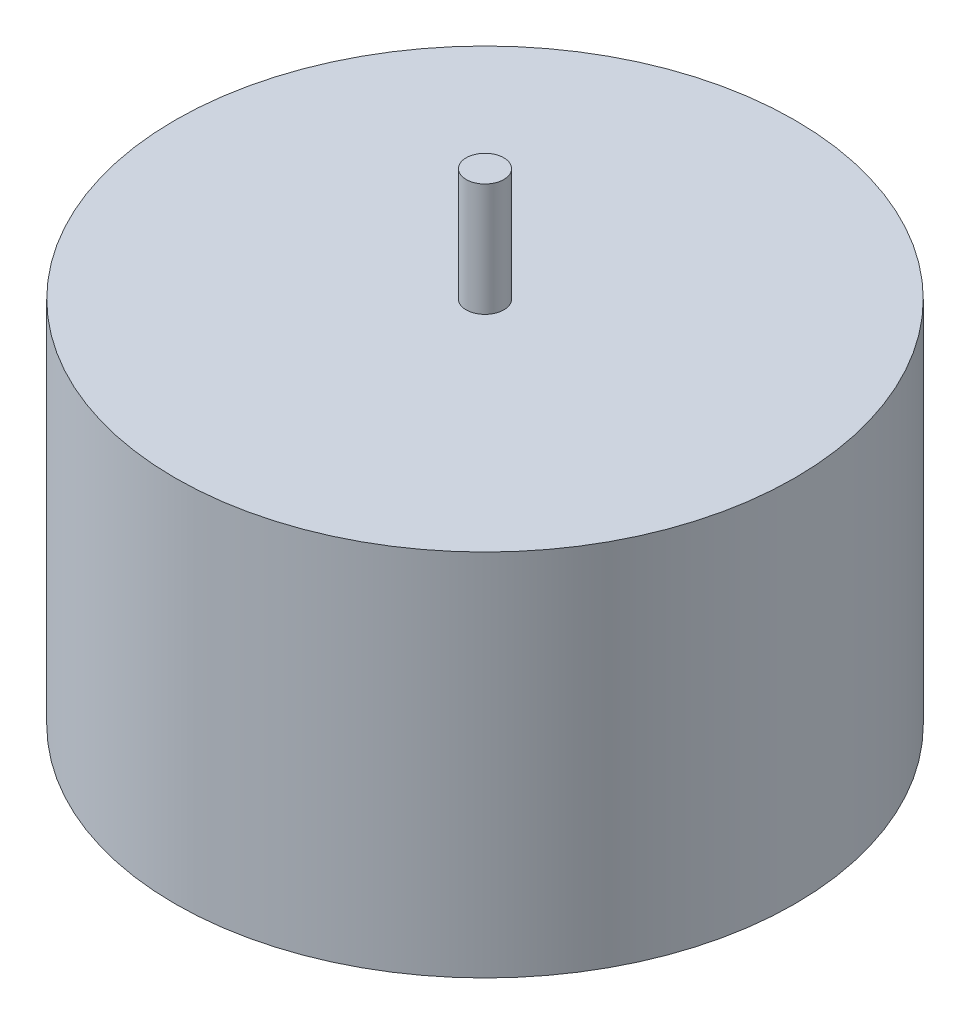
from build123d import *

# Parameters (mm, degrees)
SKETCH1_R           = 12.35
BOSS_EXTRUDE1_DEPTH = 14.7
SKETCH2_R           = 0.75
BOSS_EXTRUDE2_DEPTH = 4.5


with BuildPart() as part:
    # Sketch1 → Boss-Extrude1 (new body)
    with BuildSketch(Plane(origin=(0, 0, 0), x_dir=(1, 0, 0), z_dir=(0, 1, 0))):
        with Locations((-33.391980659, 17.663873827)):
            Circle(SKETCH1_R)
    extrude(amount=BOSS_EXTRUDE1_DEPTH)

    # Sketch2 → Boss-Extrude2 (add)
    with BuildSketch(Plane(origin=(0, 14.7, 0), x_dir=(1, 0, 0), z_dir=(0, 1, 0))):
        with Locations((-33.391980659, 17.663873827)):
            Circle(SKETCH2_R)
    extrude(amount=BOSS_EXTRUDE2_DEPTH)


solid = part.part
